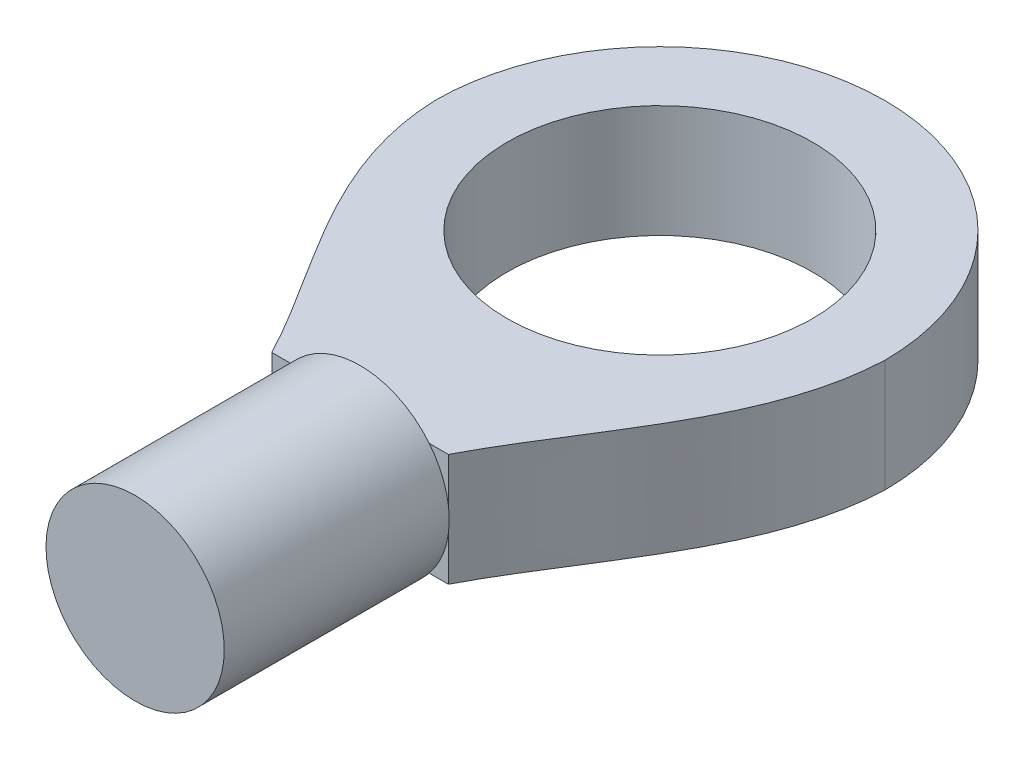
from build123d import *

# Parameters (mm, degrees)
SKETCH2_R           = 8.15
BOSS_EXTRUDE1_DEPTH = 6
SKETCH3_R           = 4.755
BOSS_EXTRUDE2_DEPTH = 12


with BuildPart() as part:
    # Sketch2 → Boss-Extrude1 (new body)
    with BuildSketch(Plane(origin=(0, 0, 0), x_dir=(1, 0, 0), z_dir=(0, 1, 0))):
        with BuildLine():
            Line((-4.71, -15.99), (4.71, -15.99))
            add(Edge.make_bspline(
                [(12, 0), (11.768004517, -6.147027332), (7.327289648, -10.952825214), (4.71, -15.99)],
                knots=[0, 0, 0, 0, 0.424868327, 0.424868327, 0.424868327, 0.424868327], degree=3))
            ThreePointArc((12, 0), (0, 12), (-12, 0))
            add(Edge.make_bspline(
                [(-12, 0), (-11.768004517, -6.147027332), (-7.327289648, -10.952825214), (-4.71, -15.99)],
                knots=[0, 0, 0, 0, 0.424868327, 0.424868327, 0.424868327, 0.424868327], degree=3))
        make_face()
        Circle(SKETCH2_R, mode=Mode.SUBTRACT)
    extrude(amount=BOSS_EXTRUDE1_DEPTH)

    # Sketch3 → Boss-Extrude2 (add)
    with BuildSketch(Plane.XY.offset(15.99)):
        with Locations((0, 3)):
            Circle(SKETCH3_R)
    extrude(amount=BOSS_EXTRUDE2_DEPTH)


solid = part.part
